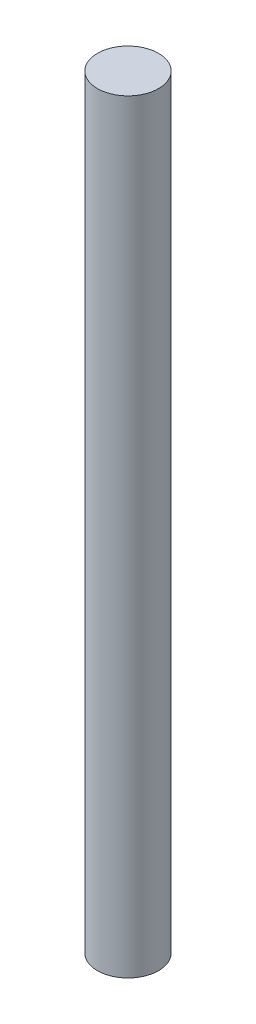
from build123d import *

# Parameters (mm, degrees)
SKETCH1_R           = 0.508
BOSS_EXTRUDE1_DEPTH = 12.7


with BuildPart() as part:
    # Sketch1 → Boss-Extrude1 (new body)
    with BuildSketch(Plane(origin=(0, 0, 0), x_dir=(1, 0, 0), z_dir=(0, 1, 0))):
        with Locations((-0.027759022, 0)):
            Circle(SKETCH1_R)
    extrude(amount=BOSS_EXTRUDE1_DEPTH)


solid = part.part
